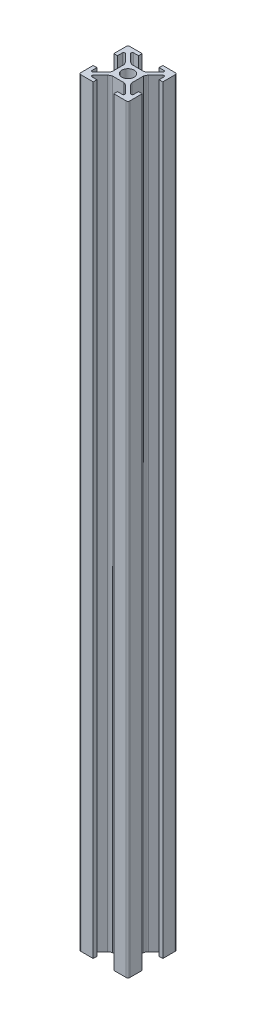
from build123d import *

# Parameters (mm, degrees)
SKETCH1_R           = 2.5
BOSS_EXTRUDE1_DEPTH = 310


with BuildPart() as part:
    # Sketch1 → Boss-Extrude1 (new body)
    with BuildSketch(Plane(origin=(0, 0, 0), x_dir=(1, 0, 0), z_dir=(0, 1, 0))):
        with BuildLine():
            Line((-3.610984523, 4.671644695), (-6.585786438, 7.646446609))
            ThreePointArc((-6.585786438, 7.646446609), (-6.694172813, 8.191341716), (-6.232233047, 8.5))
            Line((-6.232233047, 8.5), (-4.2, 8.5))
            Line((-4.2, 8.5), (-4.2, 10))
            Line((-4.2, 10), (-9.25, 10))
            ThreePointArc((-9.25, 10), (-9.780330086, 9.780330086), (-10, 9.25))
            Line((-10, 9.25), (-10, 4.2))
            Line((-10, 4.2), (-8.5, 4.2))
            Line((-8.5, 4.2), (-8.5, 6.232233047))
            ThreePointArc((-8.5, 6.232233047), (-8.191341716, 6.694172813), (-7.646446609, 6.585786438))
            Line((-7.646446609, 6.585786438), (-4.671644695, 3.610984523))
            ThreePointArc((-4.671644695, 3.610984523), (-4.244383234, 2.985253206), (-4, 2.268058063))
            Line((-4, 2.268058063), (-4, -2.268058063))
            ThreePointArc((-4, -2.268058063), (-4.244383234, -2.985253206), (-4.671644695, -3.610984523))
            Line((-4.671644695, -3.610984523), (-7.646446609, -6.585786438))
            ThreePointArc((-7.646446609, -6.585786438), (-8.191341716, -6.694172813), (-8.5, -6.232233047))
            Line((-8.5, -6.232233047), (-8.5, -4.2))
            Line((-8.5, -4.2), (-10, -4.2))
            Line((-10, -4.2), (-10, -9.25))
            ThreePointArc((-10, -9.25), (-9.780330086, -9.780330086), (-9.25, -10))
            Line((-9.25, -10), (-4.2, -10))
            Line((-4.2, -10), (-4.2, -8.5))
            Line((-4.2, -8.5), (-6.232233047, -8.5))
            ThreePointArc((-6.232233047, -8.5), (-6.694172813, -8.191341716), (-6.585786438, -7.646446609))
            Line((-6.585786438, -7.646446609), (-3.610984523, -4.671644695))
            ThreePointArc((-3.610984523, -4.671644695), (-2.985253206, -4.244383234), (-2.268058063, -4))
            Line((-2.268058063, -4), (2.268058063, -4))
            ThreePointArc((2.268058063, -4), (2.985253206, -4.244383234), (3.610984523, -4.671644695))
            Line((3.610984523, -4.671644695), (6.585786438, -7.646446609))
            ThreePointArc((6.585786438, -7.646446609), (6.694172813, -8.191341716), (6.232233047, -8.5))
            Line((6.232233047, -8.5), (4.2, -8.5))
            Line((4.2, -8.5), (4.2, -10))
            Line((4.2, -10), (9.25, -10))
            ThreePointArc((9.25, -10), (9.780330086, -9.780330086), (10, -9.25))
            Line((10, -9.25), (10, -4.2))
            Line((10, -4.2), (8.5, -4.2))
            Line((8.5, -4.2), (8.5, -6.232233047))
            ThreePointArc((8.5, -6.232233047), (8.191341716, -6.694172813), (7.646446609, -6.585786438))
            Line((7.646446609, -6.585786438), (4.671644695, -3.610984523))
            ThreePointArc((4.671644695, -3.610984523), (4.244383234, -2.985253206), (4, -2.268058063))
            Line((4, -2.268058063), (4, 2.268058063))
            ThreePointArc((4, 2.268058063), (4.244383234, 2.985253206), (4.671644695, 3.610984523))
            Line((4.671644695, 3.610984523), (7.646446609, 6.585786438))
            ThreePointArc((7.646446609, 6.585786438), (8.191341716, 6.694172813), (8.5, 6.232233047))
            Line((8.5, 6.232233047), (8.5, 4.2))
            Line((8.5, 4.2), (10, 4.2))
            Line((10, 4.2), (10, 9.25))
            ThreePointArc((10, 9.25), (9.780330086, 9.780330086), (9.25, 10))
            Line((9.25, 10), (4.2, 10))
            Line((4.2, 10), (4.2, 8.5))
            Line((4.2, 8.5), (6.232233047, 8.5))
            ThreePointArc((6.232233047, 8.5), (6.694172813, 8.191341716), (6.585786438, 7.646446609))
            Line((6.585786438, 7.646446609), (3.610984523, 4.671644695))
            ThreePointArc((3.610984523, 4.671644695), (2.985253206, 4.244383234), (2.268058063, 4))
            Line((2.268058063, 4), (-2.268058063, 4))
            ThreePointArc((-2.268058063, 4), (-2.985253206, 4.244383234), (-3.610984523, 4.671644695))
        make_face()
        Circle(SKETCH1_R, mode=Mode.SUBTRACT)
    extrude(amount=BOSS_EXTRUDE1_DEPTH)


solid = part.part
